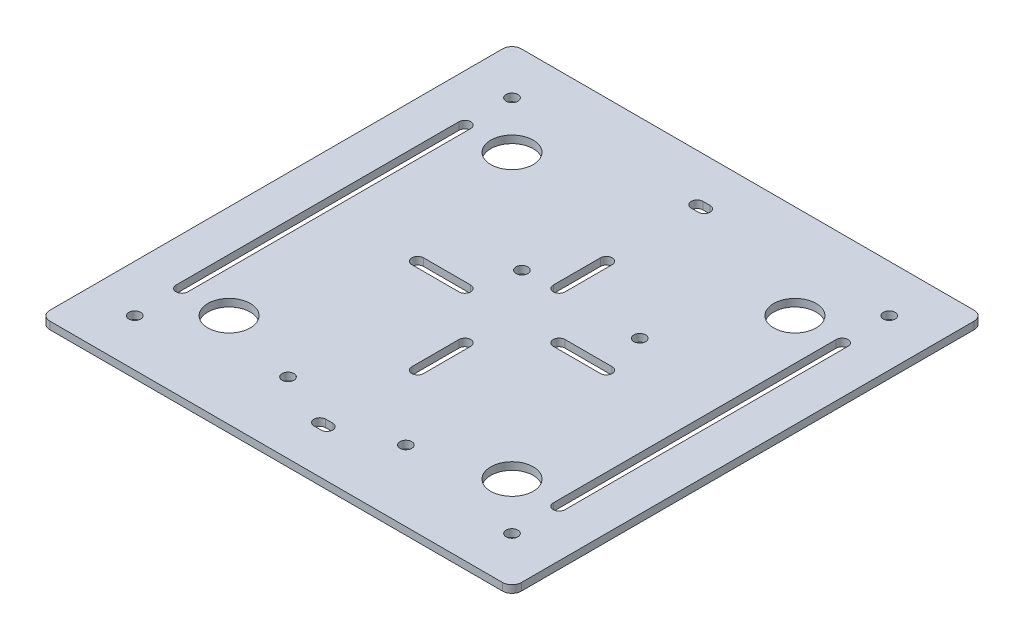
from build123d import *

# Parameters (mm, degrees)
SKETCH2_W                = 100
SKETCH2_H                = 100
BOSS_EXTRUDE1_DEPTH      = 1.5875
CUT_EXTRUDE1_DEPTH       = 5
SKETCH4_R                = 1.25
CUT_EXTRUDE2_DEPTH       = 5
CUT_EXTRUDE4_DEPTH       = 5
CUT_EXTRUDE6_DEPTH       = 5
CIRPATTERN1_COUNT        = 4
CIRPATTERN4_COUNT        = 4
FILLET2_R                = 2
F_2_5MM_DOWEL_HOLE1_D    = 2.5
F_2_5MM_DOWEL_HOLE2_D    = 2.5
F_9_0_9_DIAMETER_HOLE1_D = 9
CIRPATTERN5_COUNT        = 4


with BuildPart() as part:
    # Sketch2 → Boss-Extrude1 (new body)
    with BuildSketch(Plane(origin=(0, 0, 0), x_dir=(1, 0, 0), z_dir=(0, 1, 0))):
        with Locations((50, 50)):
            Rectangle(SKETCH2_W, SKETCH2_H)
    extrude(amount=BOSS_EXTRUDE1_DEPTH)

    # Sketch3 → Cut-Extrude1 (cut)
    with BuildSketch(Plane(origin=(0, 1.5875, 0), x_dir=(1, 0, 0), z_dir=(0, 1, 0))):
        with BuildLine():
            Line((11.25, 80), (11.25, 20))
            ThreePointArc((11.25, 20), (10, 18.75), (8.75, 20))
            Line((8.75, 20), (8.75, 80))
            ThreePointArc((8.75, 80), (10, 81.25), (11.25, 80))
        make_face()
    cut_extrude1 = extrude(amount=-CUT_EXTRUDE1_DEPTH, mode=Mode.SUBTRACT)

    # Sketch4 → Cut-Extrude2 (cut)
    with BuildSketch(Plane(origin=(0, 1.5875, 0), x_dir=(1, 0, 0), z_dir=(0, 1, 0))):
        with Locations((10, 10)):
            Circle(SKETCH4_R)
    cut_extrude2 = extrude(amount=-CUT_EXTRUDE2_DEPTH, mode=Mode.SUBTRACT)

    # Sketch6 → Cut-Extrude4 (cut)
    with BuildSketch(Plane(origin=(0, 1.5875, 0), x_dir=(1, 0, 0), z_dir=(0, 1, 0))):
        with BuildLine():
            Line((49.25, 11.25), (50.75, 11.25))
            ThreePointArc((50.75, 11.25), (52, 10), (50.75, 8.75))
            Line((50.75, 8.75), (49.25, 8.75))
            ThreePointArc((49.25, 8.75), (48, 10), (49.25, 11.25))
        make_face()
    cut_extrude4 = extrude(amount=-CUT_EXTRUDE4_DEPTH, mode=Mode.SUBTRACT)

    # Sketch8 → Cut-Extrude6 (cut)
    with BuildSketch(Plane(origin=(0, 1.5875, 0), x_dir=(1, 0, 0), z_dir=(0, 1, 0))):
        with BuildLine():
            Line((30, 51.25), (40, 51.25))
            ThreePointArc((40, 51.25), (41.25, 50), (40, 48.75))
            Line((40, 48.75), (30, 48.75))
            ThreePointArc((30, 48.75), (28.75, 50), (30, 51.25))
        make_face()
    cut_extrude6 = extrude(amount=-CUT_EXTRUDE6_DEPTH, mode=Mode.SUBTRACT)

    # Mirror3: Cut-Extrude1 across plane
    add(cut_extrude1.mirror(Plane(origin=(50, 0, 0), x_dir=(0, 0, 1), z_dir=(1, 0, 0))), mode=Mode.SUBTRACT)

    # CirPattern1: Cut-Extrude6 ×4 about axis
    cirpattern1_axis = Axis((50, 0, -50), (0, 1, 0))
    for i in range(1, CIRPATTERN1_COUNT):
        add(cut_extrude6.rotate(cirpattern1_axis, i * 360 / CIRPATTERN1_COUNT), mode=Mode.SUBTRACT)

    # CirPattern4: Cut-Extrude2 ×4 about axis
    cirpattern4_axis = Axis((50, 0, -50), (0, 1, 0))
    for i in range(1, CIRPATTERN4_COUNT):
        add(cut_extrude2.rotate(cirpattern4_axis, i * 360 / CIRPATTERN4_COUNT), mode=Mode.SUBTRACT)

    # Mirror6: Cut-Extrude4 across plane
    add(cut_extrude4.mirror(Plane(origin=(0, 0, -50), x_dir=(1, 0, 0), z_dir=(0, 0, -1))), mode=Mode.SUBTRACT)

    # Fillet2
    fillet2_edges = [part.edges().sort_by_distance(p)[0] for p in [
        (0, 0.79375, 0),
        (100, 0.79375, 0),
        (100, 0.79375, -100),
        (0, 0.79375, -100),
    ]]
    fillet(fillet2_edges, radius=FILLET2_R)

    # 2.5mm Dowel Hole1 (through all)
    with Locations(Plane(origin=(0, 1.5875, 0), x_dir=(1, 0, 0), z_dir=(0, 1, 0))):
        with Locations((62.5, 15), (37.5, 15)):
            Hole(F_2_5MM_DOWEL_HOLE1_D / 2)

    # 2.5mm Dowel Hole2 (through all)
    with Locations(Plane(origin=(0, 1.5875, 0), x_dir=(1, 0, 0), z_dir=(0, 1, 0))):
        with Locations((42.7, 59.4), (67.7, 59.4)):
            Hole(F_2_5MM_DOWEL_HOLE2_D / 2)

    # 9.0 _9_ Diameter Hole1 (through all)
    with Locations(Plane(origin=(0, 1.5875, 0), x_dir=(1, 0, 0), z_dir=(0, 1, 0))):
        with Locations((80, 20)):
            f_9_0_9_diameter_hole1 = Hole(F_9_0_9_DIAMETER_HOLE1_D / 2)

    # CirPattern5: 9.0 _9_ Diameter Hole1 ×4 about axis
    cirpattern5_axis = Axis((50, 0, -50), (0, 1, 0))
    for i in range(1, CIRPATTERN5_COUNT):
        add(f_9_0_9_diameter_hole1.rotate(cirpattern5_axis, i * 360 / CIRPATTERN5_COUNT), mode=Mode.SUBTRACT)


solid = part.part
